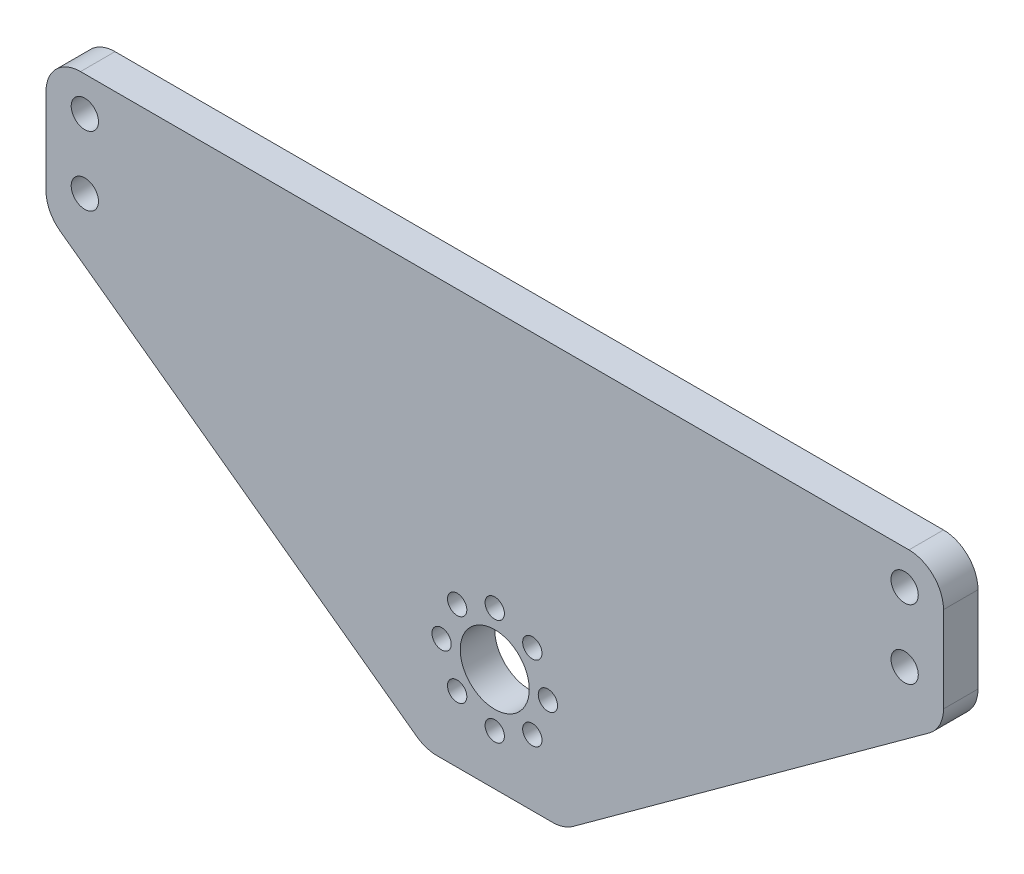
from build123d import *

# Parameters (mm, degrees)
SKETCH1_W           = 165.1
SKETCH1_H           = 76.2
SKETCH1_R           = 6.35
SKETCH1_R_2         = 2.50825
BOSS_EXTRUDE1_DEPTH = 6.35
CUT_EXTRUDE1_DEPTH  = 6.35
FILLET1_R           = 6.35
SKETCH3_R           = 1.778
CUT_EXTRUDE2_DEPTH  = 6.35
CIRPATTERN1_COUNT   = 8


with BuildPart() as part:
    # Sketch1 → Boss-Extrude1 (new body)
    with BuildSketch(Plane.XY):
        Rectangle(SKETCH1_W, SKETCH1_H)
        with Locations((0, -19.05)):
            Circle(SKETCH1_R, mode=Mode.SUBTRACT)
        with Locations((-75.40625, 31.75)):
            Circle(SKETCH1_R_2, mode=Mode.SUBTRACT)
        with Locations((75.40625, 31.75)):
            Circle(SKETCH1_R_2, mode=Mode.SUBTRACT)
        with Locations((75.40625, 19.05)):
            Circle(SKETCH1_R_2, mode=Mode.SUBTRACT)
        with Locations((-75.40625, 19.05)):
            Circle(SKETCH1_R_2, mode=Mode.SUBTRACT)
    extrude(amount=BOSS_EXTRUDE1_DEPTH)

    # Sketch2 → Cut-Extrude1 (cut)
    with BuildSketch(Plane(origin=(0, 0, 0), x_dir=(-1, 0, 0), z_dir=(0, 0, -1))):
        Polygon((12.7, -38.1), (82.55, 12.7), (82.55, -38.1), align=None)
        Polygon((-82.55, -38.1), (-82.55, 12.7), (-12.7, -38.1), align=None)
    extrude(amount=-CUT_EXTRUDE1_DEPTH, mode=Mode.SUBTRACT)

    # Fillet1
    fillet1_edges = [part.edges().sort_by_distance(p)[0] for p in [
        (-12.7, -38.1, 3.175),
        (-82.55, 12.7, 3.175),
        (12.7, -38.1, 3.175),
        (82.55, 12.7, 3.175),
        (-82.55, 38.1, 3.175),
        (82.55, 38.1, 3.175),
    ]]
    fillet(fillet1_edges, radius=FILLET1_R)

    # Sketch3 → Cut-Extrude2 (cut)
    with BuildSketch(Plane(origin=(0, 0, 0), x_dir=(-1, 0, 0), z_dir=(0, 0, -1))):
        with Locations((0, -9.271)):
            Circle(SKETCH3_R)
    cut_extrude2 = extrude(amount=-CUT_EXTRUDE2_DEPTH, mode=Mode.SUBTRACT)

    # CirPattern1: Cut-Extrude2 ×8 about axis
    cirpattern1_axis = Axis((0, -19.05, 0), (0, 0, 1))
    for i in range(1, CIRPATTERN1_COUNT):
        add(cut_extrude2.rotate(cirpattern1_axis, i * 360 / CIRPATTERN1_COUNT), mode=Mode.SUBTRACT)


solid = part.part
